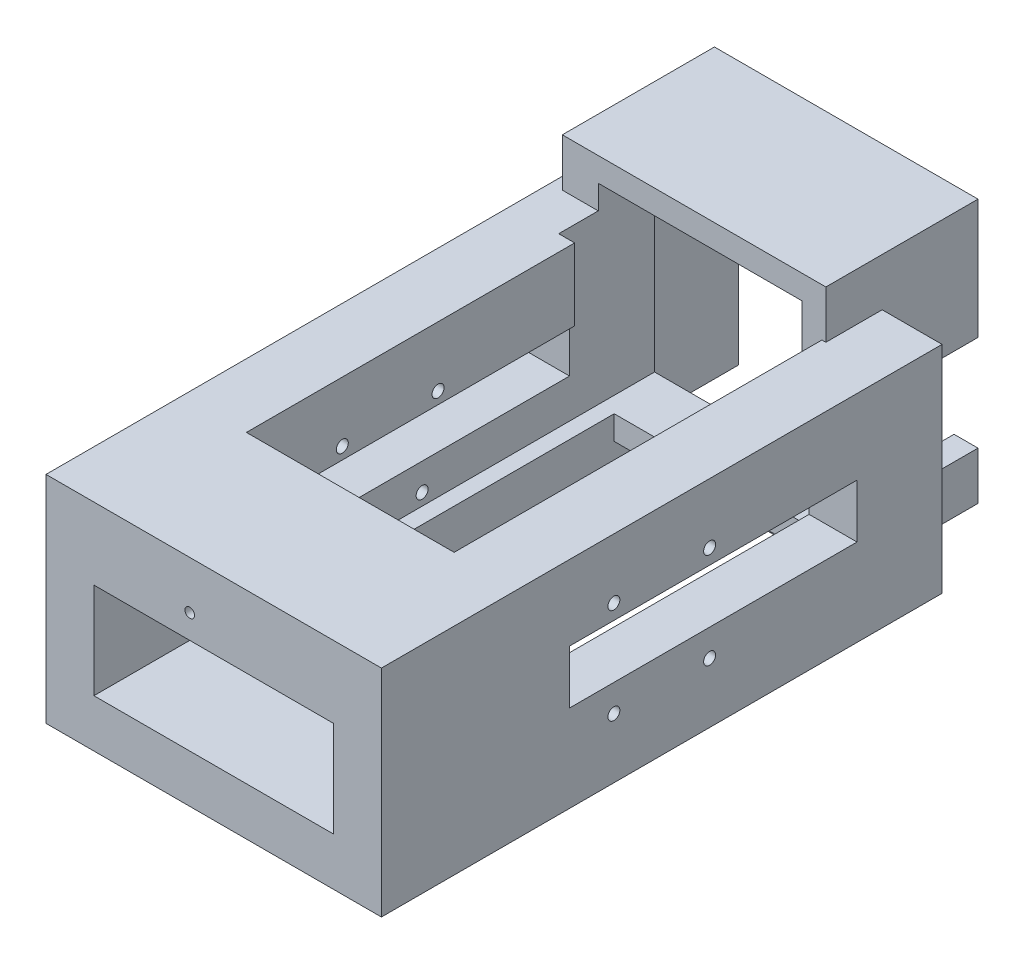
from build123d import *

# Parameters (mm, degrees)
CROQUIS1_W              = 70
CROQUIS1_H              = 117
SALIENTE_EXTRUIR1_DEPTH = 5
CROQUIS2_W              = 70
CROQUIS2_H              = 11.75
SALIENTE_EXTRUIR2_DEPTH = 40
CROQUIS5_R              = 1
CORTAR_EXTRUIR3_DEPTH   = 118
CROQUIS3_W              = 43.35
CROQUIS3_H              = 81.55
CORTAR_EXTRUIR1_DEPTH   = 10
SALIENTE_EXTRUIR4_DEPTH = 40
CROQUIS7_R              = 1.25
CROQUIS7_W              = 60
CROQUIS7_H              = 11.191024472
CORTAR_EXTRUIR5_DEPTH   = 71
CROQUIS9_W              = 50
CROQUIS9_H              = 20
CORTAR_EXTRUIR6_DEPTH   = 118
CROQUIS11_W             = 5
CROQUIS11_H             = 45
CROQUIS11_H_2           = 15
CROQUIS11_H_3           = 10
SALIENTE_EXTRUIR5_DEPTH = 20
CROQUIS12_W             = 42.5
CROQUIS12_H             = 15
CORTAR_EXTRUIR7_DEPTH   = 20
CROQUIS13_W             = 5
CROQUIS13_H             = 31.75
SALIENTE_EXTRUIR6_DEPTH = 5
CROQUIS14_W             = 55
CROQUIS14_H             = 31.75
SALIENTE_EXTRUIR7_DEPTH = 5


with BuildPart() as part:
    # Croquis1 → Saliente-Extruir1 (new body)
    with BuildSketch(Plane(origin=(0, 0, 0), x_dir=(1, 0, 0), z_dir=(0, 1, 0))):
        Rectangle(CROQUIS1_W, CROQUIS1_H)
    extrude(amount=SALIENTE_EXTRUIR1_DEPTH)

    # Croquis2 → Saliente-Extruir2 (add)
    with BuildSketch(Plane(origin=(0, 5, 0), x_dir=(1, 0, 0), z_dir=(0, 1, 0))):
        with Locations((0, 52.625)):
            Rectangle(CROQUIS2_W, CROQUIS2_H)
        with Locations((0, -52.625)):
            Rectangle(CROQUIS2_W, CROQUIS2_H)
    extrude(amount=SALIENTE_EXTRUIR2_DEPTH)

    # Croquis5 → Cortar-Extruir3 (cut, through all)
    with BuildSketch(Plane(origin=(0, 0, -58.5), x_dir=(-1, 0, 0), z_dir=(0, 0, -1))):
        with Locations((5, 35)):
            Circle(CROQUIS5_R)
    extrude(amount=-CORTAR_EXTRUIR3_DEPTH, mode=Mode.SUBTRACT)

    # Croquis3 → Cortar-Extruir1 (cut)
    with BuildSketch(Plane(origin=(0, 5, 0), x_dir=(1, 0, 0), z_dir=(0, 1, 0))):
        with Locations((0, 10.775)):
            Rectangle(CROQUIS3_W, CROQUIS3_H)
    extrude(amount=-CORTAR_EXTRUIR1_DEPTH, mode=Mode.SUBTRACT)

    # Croquis8 → Saliente-Extruir4 (add)
    with BuildSketch(Plane(origin=(0, 5, 0), x_dir=(1, 0, 0), z_dir=(0, 1, 0))):
        Polygon((35, -46.75), (35, 46.75), (21.675, 46.75), (21.675, -30), (-21.675, -30), (-21.675, 46.75), (-35, 46.75), (-35, -46.75), align=None)
    extrude(amount=SALIENTE_EXTRUIR4_DEPTH)

    # Croquis7 → Cortar-Extruir5 (cut, through all)
    with BuildSketch(Plane.ZY.offset(35)):
        with Locations((-9.99, 32.49)):
            Circle(CROQUIS7_R)
        with Locations((9.99, 32.49)):
            Circle(CROQUIS7_R)
        with Locations((9.99, 12.51)):
            Circle(CROQUIS7_R)
        with Locations((-9.99, 12.51)):
            Circle(CROQUIS7_R)
        with Locations((-10.75, 23.745325958)):
            Rectangle(CROQUIS7_W, CROQUIS7_H)
    extrude(amount=-CORTAR_EXTRUIR5_DEPTH, mode=Mode.SUBTRACT)

    # Croquis9 → Cortar-Extruir6 (cut, through all)
    with BuildSketch(Plane.XY.offset(58.5)):
        with Locations((0, 20)):
            Rectangle(CROQUIS9_W, CROQUIS9_H)
    extrude(amount=-CORTAR_EXTRUIR6_DEPTH, mode=Mode.SUBTRACT)

    # Croquis11 → Saliente-Extruir5 (add)
    with BuildSketch(Plane(origin=(0, 0, -58.5), x_dir=(-1, 0, 0), z_dir=(0, 0, -1))):
        with Locations((30, 22.5)):
            Rectangle(CROQUIS11_W, CROQUIS11_H)
        with Locations((-20, 37.5)):
            Rectangle(CROQUIS11_W, CROQUIS11_H_2)
        with Locations((-20, 5)):
            Rectangle(CROQUIS11_W, CROQUIS11_H_3)
    extrude(amount=SALIENTE_EXTRUIR5_DEPTH)

    # Croquis12 → Cortar-Extruir7 (cut)
    with BuildSketch(Plane(origin=(0, 0, -58.5), x_dir=(-1, 0, 0), z_dir=(0, 0, -1))):
        with Locations((3.75, 37.5)):
            Rectangle(CROQUIS12_W, CROQUIS12_H)
    extrude(amount=-CORTAR_EXTRUIR7_DEPTH, mode=Mode.SUBTRACT)

    # Croquis13 → Saliente-Extruir6 (add)
    with BuildSketch(Plane(origin=(0, 45, 0), x_dir=(1, 0, 0), z_dir=(0, 1, 0))):
        Polygon((-32.5, 78.5), (-27.5, 78.5), (-27.5, 58.5), (-25, 58.5), (-25, 46.75), (-32.5, 46.75), align=None)
        with Locations((20, 62.625)):
            Rectangle(CROQUIS13_W, CROQUIS13_H)
    extrude(amount=SALIENTE_EXTRUIR6_DEPTH)

    # Croquis14 → Saliente-Extruir7 (add)
    with BuildSketch(Plane(origin=(0, 50, 0), x_dir=(1, 0, 0), z_dir=(0, 1, 0))):
        with Locations((-5, 62.625)):
            Rectangle(CROQUIS14_W, CROQUIS14_H)
    extrude(amount=SALIENTE_EXTRUIR7_DEPTH)


solid = part.part
